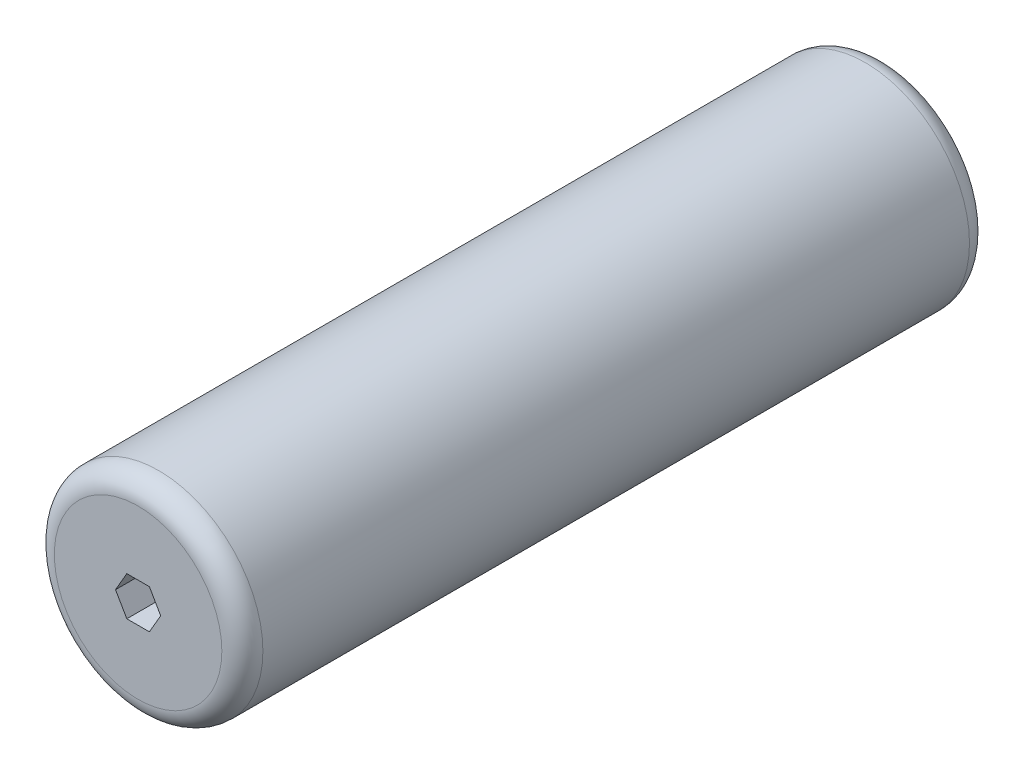
from build123d import *

# Parameters (mm, degrees)
SKETCH1_R           = 25.4
BOSS_EXTRUDE1_DEPTH = 182.118
CUT_EXTRUDE1_DEPTH  = 183.118
FILLET1_R           = 5


with BuildPart() as part:
    # Sketch1 → Boss-Extrude1 (new body)
    with BuildSketch(Plane.XY):
        Circle(SKETCH1_R)
    extrude(amount=BOSS_EXTRUDE1_DEPTH)

    # Sketch2 → Cut-Extrude1 (cut, through all)
    with BuildSketch(Plane.XY.offset(182.118)):
        Polygon((5.499261314, 0), (2.749630657, 4.7625), (-2.749630657, 4.7625), (-5.499261314, 0), (-2.749630657, -4.7625), (2.749630657, -4.7625), align=None)
    extrude(amount=-CUT_EXTRUDE1_DEPTH, mode=Mode.SUBTRACT)

    # Fillet1
    fillet1_edges = [part.edges().sort_by_distance(p)[0] for p in [
        (-25.4, 0, 0),
        (-25.4, 0, 182.118),
    ]]
    fillet(fillet1_edges, radius=FILLET1_R)


solid = part.part
